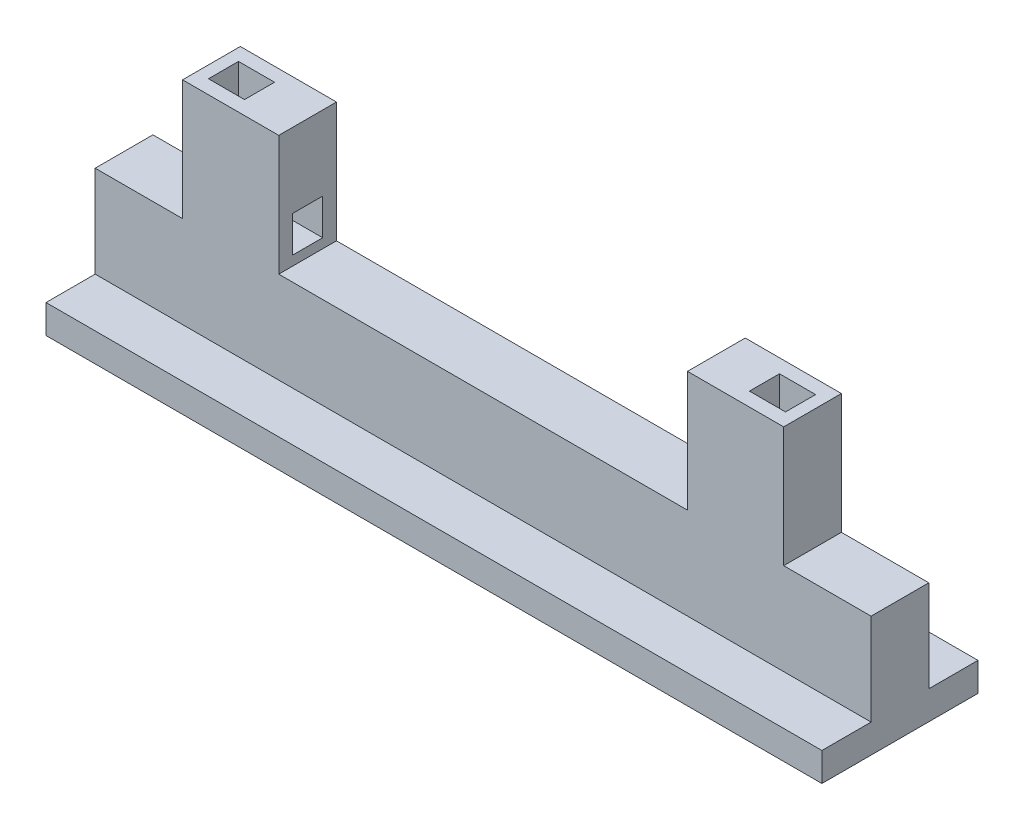
from build123d import *

# Parameters (mm, degrees)
SKETCH3_W           = 12.984343194
SKETCH3_H           = 2.380771229
SKETCH3_W_2         = 4.803091943
SKETCH3_H_2         = 9.313818956
BOSS_EXTRUDE2_DEPTH = 32.27
SKETCH6_W           = 8
SKETCH6_H           = 4.803091943
BOSS_EXTRUDE3_DEPTH = 10
CUT_EXTRUDE2_DEPTH  = 1.25
FILLET1_R           = 3


with BuildPart() as part:
    # Sketch3 → Boss-Extrude2 (new body)
    with BuildSketch(Plane(origin=(0, 0, 0), x_dir=(0, 0, -1), z_dir=(1, 0, 0))):
        with Locations((0.543022473, -13.14020457)):
            Rectangle(SKETCH3_W, SKETCH3_H)
        with Locations((0.543022474, -8.974909478)):
            Rectangle(SKETCH3_W_2, SKETCH3_H_2)
    boss_extrude2 = extrude(amount=BOSS_EXTRUDE2_DEPTH)

    # Sketch6 → Boss-Extrude3 (add)
    with BuildSketch(Plane(origin=(0, -4.318, 0), x_dir=(1, 0, 0), z_dir=(0, 1, 0))):
        with Locations((11.27, 0.543022474)):
            Rectangle(SKETCH6_W, SKETCH6_H)
    boss_extrude3 = extrude(amount=BOSS_EXTRUDE3_DEPTH)

    # Sketch7 → Cut-Extrude2 (cut, symmetric)
    with BuildSketch(Plane.XY.offset(-0.543022473)):
        with BuildLine():
            Line((11.27, 5.682), (8.27, 5.682))
            Line((8.27, 5.682), (8.27, -0.520355546))
            ThreePointArc((8.27, -0.520355546), (9.148679656, -2.64167589), (11.27, -3.520355546))
            Line((11.27, -3.520355546), (15.27, -3.520355546))
            Line((15.27, -3.520355546), (15.27, -0.520355546))
            Line((15.27, -0.520355546), (11.27, -0.520355546))
            Line((11.27, -0.520355546), (11.27, 5.682))
        make_face()
    cut_extrude2 = extrude(amount=CUT_EXTRUDE2_DEPTH, both=True, mode=Mode.SUBTRACT)

    # Fillet1
    fillet1_edges = [part.edges().sort_by_distance(p)[0] for p in [
        (11.27, -0.520355546, -0.543022473),
    ]]
    fillet(fillet1_edges, radius=FILLET1_R)

    # Mirror2: Boss-Extrude2, Boss-Extrude3, Cut-Extrude2 across plane
    add(boss_extrude2.mirror(Plane.ZY.offset(-32.27)))
    add(boss_extrude3.mirror(Plane.ZY.offset(-32.27)))
    add(cut_extrude2.mirror(Plane.ZY.offset(-32.27)), mode=Mode.SUBTRACT)


solid = part.part
